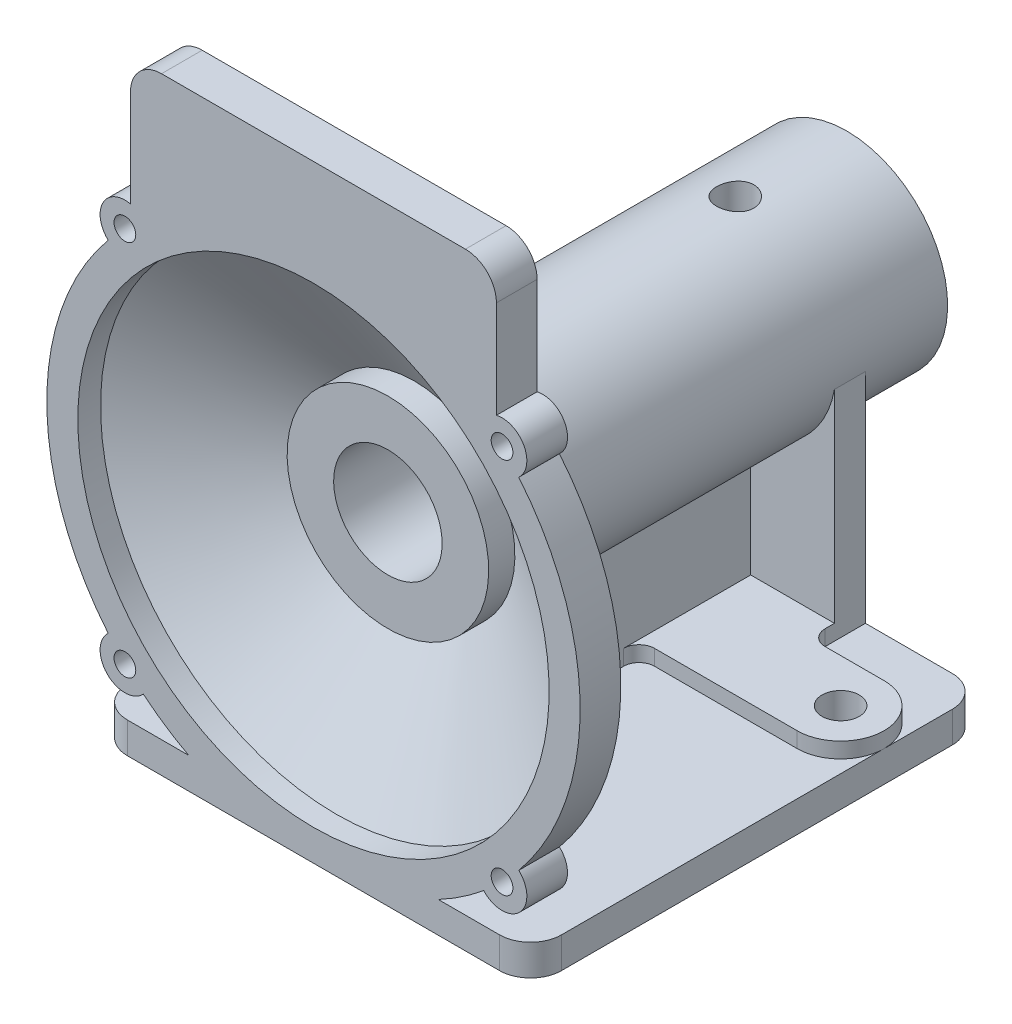
from build123d import *

# Parameters (mm, degrees)
SKETCH2_W               = 140
SKETCH2_H               = 146
BOSS_EXTRUDE1_DEPTH     = 10
RIB1_REACH              = 212.656
SKETCH3_WALL_W          = 466.812236738
SKETCH3_WALL_H          = 10
BOSS_EXTRUDE2_DEPTH     = 10
BOSS_EXTRUDE3_REACH     = 276.583
SKETCH5_W               = 118
SKETCH5_H               = 13.111760598
BOSS_EXTRUDE4_DEPTH     = 5
SKETCH7_R               = 6
CUT_EXTRUDE1_DEPTH      = 265.085213911
SKETCH8_R               = 8
BOSS_EXTRUDE5_DEPTH     = 13.111760598
CUT_EXTRUDE2_REACH      = 223.54
SKETCH9_R               = 3.5
SKETCH10_R              = 15
CUT_EXTRUDE3_DEPTH      = 224.528522172
CUT_EXTRUDE4_REACH      = 223.54
CUT_EXTRUDE4_END_RADIUS = 32.5
SKETCH11_R              = 6
FILLET3_R               = 10
FILLET4_R               = 5
FILLET5_R               = 10


with BuildPart() as part:
    # Sketch1 → Revolve1 (revolve)
    with BuildSketch(Plane(origin=(0, 0, 0), x_dir=(0, 0, -1), z_dir=(1, 0, 0))):
        Polygon((0, 32.5), (-128, 32.5), (-158.888239402, 86), (-172, 86), (-172, 76), (-164.661742094, 76), (-139.547005384, 32.5), (-148, 32.5), (-148, 17.5), (-100, 17.5), (-100, 21), (-50, 21), (-50, 17.5), (0, 17.5), align=None)
    revolve(axis=Axis((0, 0, 0), (0, 0, 1)))

    # Sketch2 → Boss-Extrude1 (add)
    with BuildSketch(Plane(origin=(0, -86, 0), x_dir=(1, 0, 0), z_dir=(0, 1, 0))):
        with Locations((0, -99)):
            Rectangle(SKETCH2_W, SKETCH2_H)
    extrude(amount=BOSS_EXTRUDE1_DEPTH)

    # Sketch3 wall → Rib1 (add, up to next)
    with BuildSketch(Plane(origin=(0, -54.25, 26), x_dir=(0, 1, 0), z_dir=(0, 0, 1)), mode=Mode.PRIVATE) as rib1_sk1:
        Rectangle(SKETCH3_WALL_W, SKETCH3_WALL_H)
    rib1_tool1 = extrude(rib1_sk1.sketch, amount=RIB1_REACH, mode=Mode.PRIVATE) - part.part
    add(rib1_tool1.solids().sort_by_distance((0, -54.25, 26))[0])

    # Sketch4 → Boss-Extrude2 (add)
    with BuildSketch(Plane(origin=(0, 0, 26), x_dir=(-1, 0, 0), z_dir=(0, 0, -1))):
        with BuildLine():
            Line((-32, -76), (-32, -5.678908346))
            ThreePointArc((-32, -5.678908346), (-22.736344844, -23.223019251), (-5, -32.113081447))
            ThreePointArc((-5, -32.113081447), (0, -32.5), (5, -32.113081447))
            ThreePointArc((5, -32.113081447), (22.736344844, -23.223019251), (32, -5.678908346))
            Line((32, -5.678908346), (32, -76))
            Line((32, -76), (-32, -76))
        make_face()
    extrude(amount=-BOSS_EXTRUDE2_DEPTH)

    # Sketch5 → Boss-Extrude3 (add, up to next)
    with BuildSketch(Plane(origin=(0, 110, 0), x_dir=(1, 0, 0), z_dir=(0, 1, 0)), mode=Mode.PRIVATE) as boss_extrude3_sk1:
        with Locations((0, -165.444119701)):
            Rectangle(SKETCH5_W, SKETCH5_H)
    boss_extrude3_tool1 = extrude(boss_extrude3_sk1.sketch, amount=-BOSS_EXTRUDE3_REACH, mode=Mode.PRIVATE) - part.part
    add(boss_extrude3_tool1.solids().sort_by_distance((0, 110, 165.44412))[0])

    # Sketch6 → Boss-Extrude4 (add)
    with BuildSketch(Plane(origin=(0, -76, 0), x_dir=(1, 0, 0), z_dir=(0, 1, 0))):
        with BuildLine():
            Line((5, -36), (5, -72))
            Line((5, -72), (56, -72))
            ThreePointArc((56, -72), (70, -58), (56, -44))
            Line((56, -44), (32, -44))
            Line((32, -44), (32, -36))
            Line((32, -36), (5, -36))
        make_face()
    boss_extrude4 = extrude(amount=BOSS_EXTRUDE4_DEPTH)

    # Sketch7 → Cut-Extrude1 (cut, through all)
    with BuildSketch(Plane(origin=(0, -71, 0), x_dir=(1, 0, 0), z_dir=(0, 1, 0))):
        with Locations(Location((56, -58, 0), (0, 0, 270))):
            Circle(SKETCH7_R)
    cut_extrude1 = extrude(amount=-CUT_EXTRUDE1_DEPTH, mode=Mode.SUBTRACT)

    # Mirror1: Boss-Extrude4, Cut-Extrude1 across plane
    add(boss_extrude4.mirror(Plane(origin=(0, 0, 0), x_dir=(0, 0, 1), z_dir=(1, 0, 0))))
    add(cut_extrude1.mirror(Plane(origin=(0, 0, 0), x_dir=(0, 0, 1), z_dir=(1, 0, 0))), mode=Mode.SUBTRACT)

    # Sketch8 → Boss-Extrude5 (add)
    with BuildSketch(Plane.XY.offset(172)):
        with Locations((-60.811183182, 60.811183182)):
            Circle(SKETCH8_R)
        with Locations((60.811183182, 60.811183182)):
            Circle(SKETCH8_R)
    boss_extrude5 = extrude(amount=-BOSS_EXTRUDE5_DEPTH)

    # Sketch9 → Cut-Extrude2 (cut, up to next)
    with BuildSketch(Plane.XY.offset(172), mode=Mode.PRIVATE) as cut_extrude2_sk1:
        with Locations((-60.811183182, 60.811183182)):
            Circle(SKETCH9_R)
    cut_extrude2_tool1 = extrude(cut_extrude2_sk1.sketch, amount=-CUT_EXTRUDE2_REACH, mode=Mode.PRIVATE) & part.part
    # Sketch9 → Cut-Extrude2 (cut, up to next)
    with BuildSketch(Plane.XY.offset(172), mode=Mode.PRIVATE) as cut_extrude2_sk2:
        with Locations((60.811183182, 60.811183182)):
            Circle(SKETCH9_R)
    cut_extrude2_tool2 = extrude(cut_extrude2_sk2.sketch, amount=-CUT_EXTRUDE2_REACH, mode=Mode.PRIVATE) & part.part
    cut_extrude2_1 = cut_extrude2_tool1.solids().sort_by_distance((-60.811183, 60.811183, 172))[0]
    add(cut_extrude2_1, mode=Mode.SUBTRACT)
    cut_extrude2_2 = cut_extrude2_tool2.solids().sort_by_distance((60.811183, 60.811183, 172))[0]
    add(cut_extrude2_2, mode=Mode.SUBTRACT)
    cut_extrude2 = cut_extrude2_1 + cut_extrude2_2  # Cut-Extrude2 as one shape, for the pattern or mirror that repeats it

    # Mirror2: Boss-Extrude5, Cut-Extrude2 across plane
    add(boss_extrude5.mirror(Plane.ZX))
    add(cut_extrude2.mirror(Plane.ZX), mode=Mode.SUBTRACT)

    # Sketch10 → Cut-Extrude3 (cut, through all)
    with BuildSketch(Plane(origin=(5, 0, 0), x_dir=(0, 0, -1), z_dir=(1, 0, 0))):
        with Locations((-114, -56)):
            Circle(SKETCH10_R)
    extrude(amount=-CUT_EXTRUDE3_DEPTH, mode=Mode.SUBTRACT)

    # Cut-Extrude4: up to this cylinder (the profile starts inside it)
    cut_extrude4_end = Plane(origin=(0, 0, 36), z_dir=(0, 0, -1)) * Cylinder(CUT_EXTRUDE4_END_RADIUS, 513.08, mode=Mode.PRIVATE)
    # Sketch11 → Cut-Extrude4 (cut, up to the surface)
    with BuildSketch(Plane(origin=(0, 0, 0), x_dir=(1, 0, 0), z_dir=(0, 1, 0)), mode=Mode.PRIVATE) as cut_extrude4_sk1:
        with Locations(Location((0, -36, 0), (0, 0, 90))):
            Circle(SKETCH11_R)
    cut_extrude4_tool1 = extrude(cut_extrude4_sk1.sketch, amount=CUT_EXTRUDE4_REACH, mode=Mode.PRIVATE) & cut_extrude4_end
    add(cut_extrude4_tool1.solids().sort_by_distance((0, 0, 36))[0], mode=Mode.SUBTRACT)

    # Fillet3
    fillet3_edges = [part.edges().sort_by_distance(p)[0] for p in [
        (-59, 110, 165.444119701),
        (59, 110, 165.444119701),
    ]]
    fillet(fillet3_edges, radius=FILLET3_R)

    # Fillet4
    fillet4_edges = [part.edges().sort_by_distance(p)[0] for p in [
        (32, -73.5, 44),
        (5, -73.5, 72),
        (-5, -73.5, 72),
        (-32, -73.5, 44),
    ]]
    fillet(fillet4_edges, radius=FILLET4_R)

    # Fillet5
    fillet5_edges = [part.edges().sort_by_distance(p)[0] for p in [
        (-70, -81, 172),
        (-70, -81, 26),
        (70, -81, 172),
        (70, -81, 26),
    ]]
    fillet(fillet5_edges, radius=FILLET5_R)


solid = part.part
